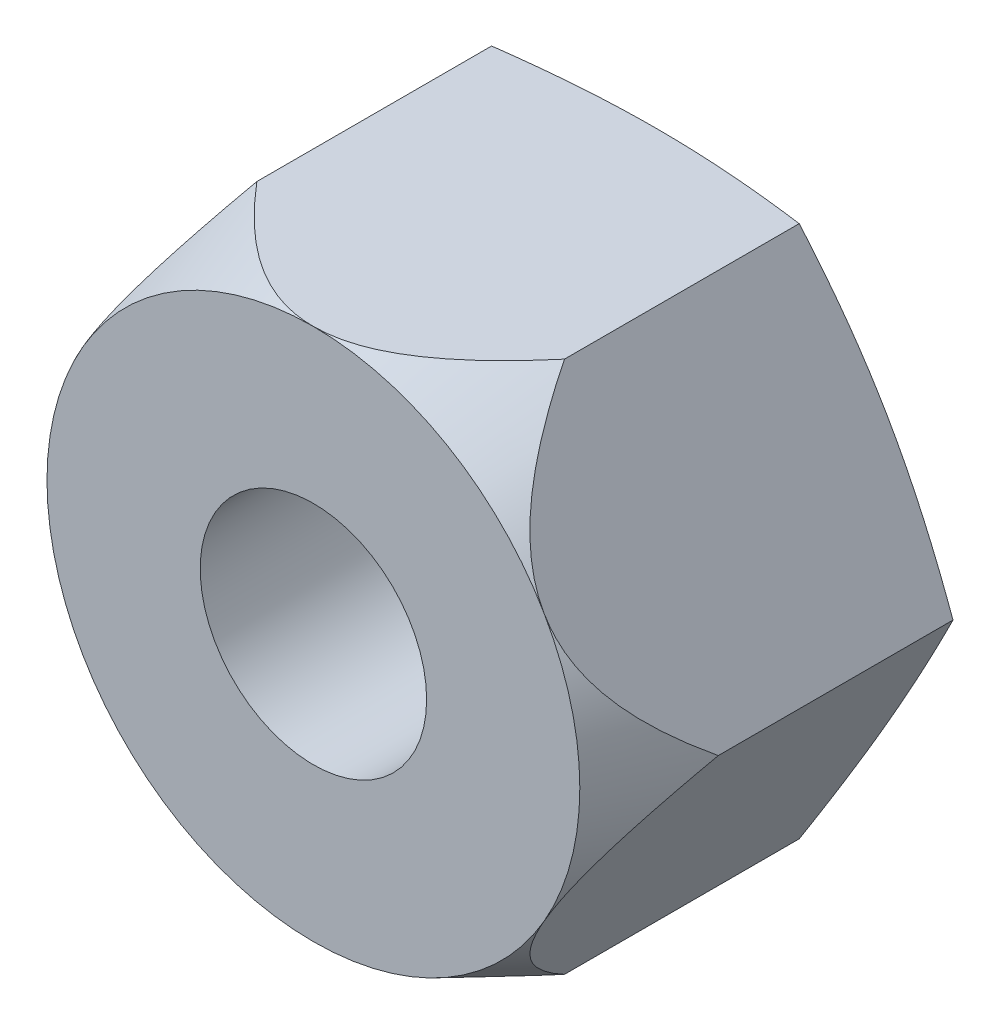
from build123d import *

# Parameters (mm, degrees)
BASENUT_DEPTH   = 5.3
SKETCH3_R       = 1.7
HOLE_DEPTH      = 6.3
ENDCHAMFER_SIZE = 0.485714286


with BuildPart() as part:
    # Sketch1 → BaseNut (new body)
    with BuildSketch(Plane.XY):
        Polygon((2.309401077, -4), (4.618802154, 0), (2.309401077, 4), (-2.309401077, 4), (-4.618802154, 0), (-2.309401077, -4), align=None)
    extrude(amount=-BASENUT_DEPTH)

    # Sketch2 → Double-Chamfer (revolve, cut)
    with BuildSketch(Plane(origin=(0.481162538, 0, -5.099964691), x_dir=(0, 0, -1), z_dir=(0, -1, 0))):
        Polygon((-0.115823776, 4.137639616), (0.200035309, 4.137639616), (0.200035309, 2.958837462), align=None)
        Polygon((-5.099964691, 4.137639616), (-3.639964691, 4.137639616), (-5.099964691, 3.518837462), align=None)
    revolve(axis=Axis((0, 0, -4.462865094), (0, 0, 1)), mode=Mode.SUBTRACT)

    # Sketch3 → Hole (cut, through all)
    with BuildSketch(Plane.XY):
        Circle(SKETCH3_R)
    extrude(amount=-HOLE_DEPTH, mode=Mode.SUBTRACT)

    # EndChamfer
    endchamfer_edges = [part.edges().sort_by_distance(p)[0] for p in [
        (-1.7, 0, -5.3),
    ]]
    chamfer(endchamfer_edges, length=ENDCHAMFER_SIZE)


solid = part.part
